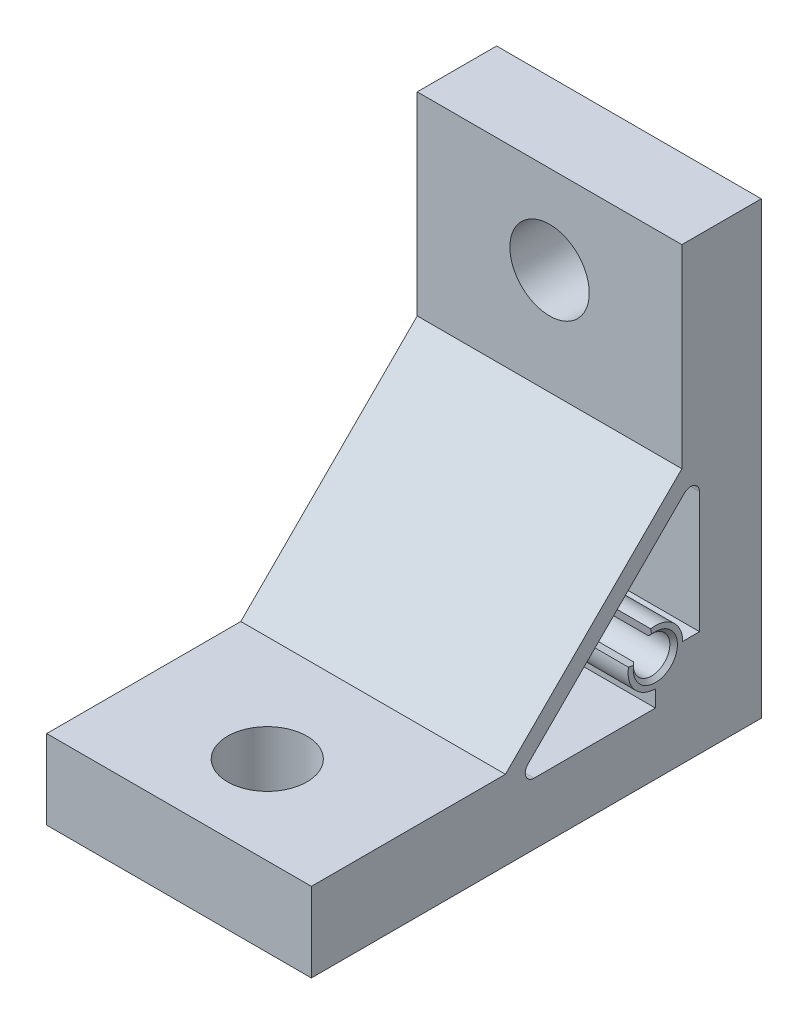
from build123d import *

# Parameters (mm, degrees)
SKETCH1_W                    = 51
SKETCH1_H                    = 51
BOSS_EXTRUDE1_DEPTH          = 30
CUT_EXTRUDE1_DEPTH           = 31
CUT_EXTRUDE2_DEPTH           = 31
SKETCH4_W                    = 30
SKETCH4_H                    = 2.067
F_9_0_9_DIAMETER_HOLE1_D     = 9
F_9_0_9_DIAMETER_HOLE1_DEPTH = 9
F_9_0_9_DIAMETER_HOLE2_D     = 9
F_9_0_9_DIAMETER_HOLE2_DEPTH = 9
CHAMFER1_SIZE                = 0.433


with BuildPart() as part:
    # Sketch1 → Boss-Extrude1 (new body)
    with BuildSketch(Plane(origin=(15, 0, 0), x_dir=(0, 0, -1), z_dir=(1, 0, 0))):
        with Locations((-25.5, 25.5)):
            Rectangle(SKETCH1_W, SKETCH1_H)
    extrude(amount=-BOSS_EXTRUDE1_DEPTH)

    # Sketch2 → Cut-Extrude1 (cut, through all)
    with BuildSketch(Plane.ZY.offset(15)):
        Polygon((9, 51), (9, 29), (29, 9), (51, 9), (51, 51), align=None)
    extrude(amount=-CUT_EXTRUDE1_DEPTH, mode=Mode.SUBTRACT)

    # Sketch3 → Cut-Extrude2 (cut, through all)
    with BuildSketch(Plane.ZY.offset(15)):
        with BuildLine():
            Line((12, 8.9), (12, 7))
            Line((12, 7), (25.757359313, 7))
            ThreePointArc((25.757359313, 7), (26.681238845, 7.617316568), (26.464466094, 8.707106781))
            Line((26.464466094, 8.707106781), (8.707106781, 26.464466094))
            ThreePointArc((8.707106781, 26.464466094), (7.617316568, 26.681238845), (7, 25.757359313))
            Line((7, 25.757359313), (7, 12))
            Line((7, 12), (8.9, 12))
            ThreePointArc((8.9, 12), (10.00735841, 14.374737774), (12.538309351, 15.052904034))
            Line((12.538309351, 15.052904034), (12.364661173, 14.068096281))
            ThreePointArc((12.364661173, 14.068096281), (11.523597358, 11.523597358), (14.068096281, 12.364661173))
            Line((14.068096281, 12.364661173), (15.052904034, 12.538309351))
            ThreePointArc((15.052904034, 12.538309351), (14.374737774, 10.00735841), (12, 8.9))
        make_face()
    extrude(amount=-CUT_EXTRUDE2_DEPTH, mode=Mode.SUBTRACT)

    # Sketch4 → Cut-Revolve1 (revolve, cut)
    with BuildSketch(Plane.XY.offset(12)):
        with Locations((0, 13.0335)):
            Rectangle(SKETCH4_W, SKETCH4_H)
    revolve(axis=Axis((-15, 12, 12), (1, 0, 0)), mode=Mode.SUBTRACT)

    # Ø9.0 (9) Diameter Hole1
    with Locations(Plane.XY.offset(9)):
        with Locations((0, 41)):
            Hole(F_9_0_9_DIAMETER_HOLE1_D / 2, depth=F_9_0_9_DIAMETER_HOLE1_DEPTH)

    # Ø9.0 (9) Diameter Hole2
    with Locations(Plane(origin=(0, 9, 0), x_dir=(1, 0, 0), z_dir=(0, 1, 0))):
        with Locations((0, -41)):
            Hole(F_9_0_9_DIAMETER_HOLE2_D / 2, depth=F_9_0_9_DIAMETER_HOLE2_DEPTH)

    # Chamfer1
    chamfer1_edges = [part.edges().sort_by_distance(p)[0] for p in [
        (15, 14.059848355, 12.31475481),
        (15, 10.538410283, 10.538410283),
    ]]
    chamfer(chamfer1_edges, length=CHAMFER1_SIZE)


solid = part.part
